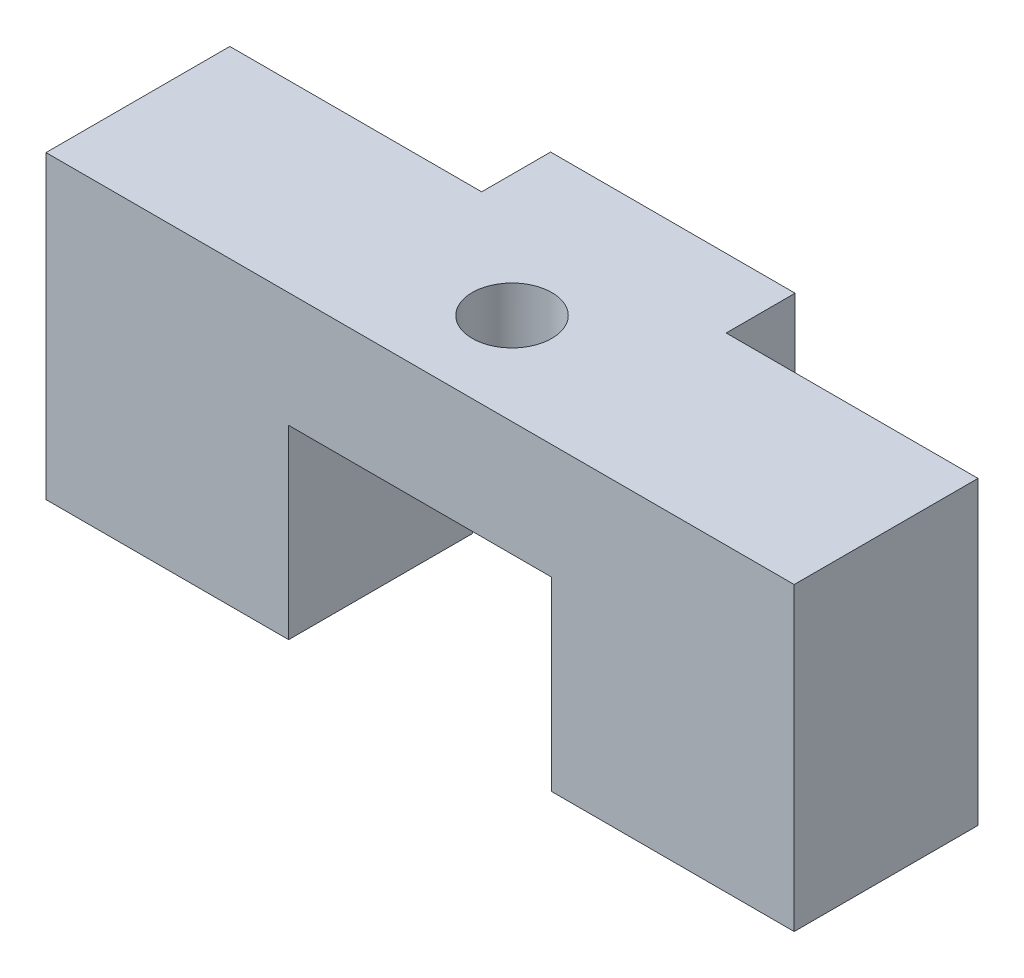
from build123d import *

# Parameters (mm, degrees)
BOSS_EXTRUDE1_DEPTH  = 3.175
SKETCH2_W            = 6.7056
SKETCH2_H            = 5.08
BOSS_EXTRUDE2_DEPTH  = 5.1308
M2_CLEARANCE_HOLE1_D = 2.2


with BuildPart() as part:
    # Sketch1 → Boss-Extrude1 (new body)
    with BuildSketch(Plane(origin=(0, 0, 0), x_dir=(1, 0, 0), z_dir=(0, 1, 0))):
        Polygon((0, 0), (20.6756, 0), (20.6756, 5.08), (13.716, 5.08), (13.716, 6.985), (6.9596, 6.985), (6.9596, 5.08), (0, 5.08), align=None)
    extrude(amount=BOSS_EXTRUDE1_DEPTH)

    # Sketch2 → Boss-Extrude2 (add)
    with BuildSketch(Plane.XZ):
        with Locations((17.3228, -2.54)):
            Rectangle(SKETCH2_W, SKETCH2_H)
        with Locations((3.3528, -2.54)):
            Rectangle(SKETCH2_W, SKETCH2_H)
    extrude(amount=BOSS_EXTRUDE2_DEPTH)

    # M2 Clearance Hole1 (through all)
    with Locations(Plane(origin=(0, 3.175, 0), x_dir=(1, 0, 0), z_dir=(0, 1, 0))):
        with Locations((10.3378, 2.54)):
            Hole(M2_CLEARANCE_HOLE1_D / 2)


solid = part.part
